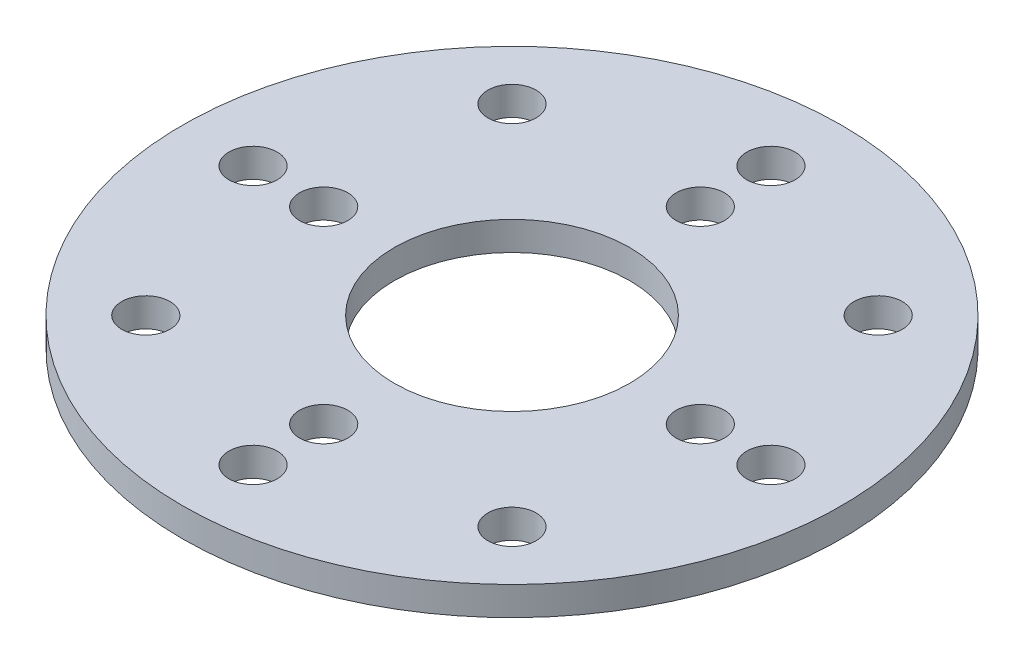
from build123d import *

# Parameters (mm, degrees)
SKETCH1_R           = 14
SKETCH1_R_2         = 1.025
SKETCH1_R_3         = 5
BOSS_EXTRUDE1_DEPTH = 1.22


with BuildPart() as part:
    # Sketch1 → Boss-Extrude1 (new body)
    with BuildSketch(Plane(origin=(0, 1.72, 0), x_dir=(1, 0, 0), z_dir=(0, 1, 0))):
        Circle(SKETCH1_R)
        with Locations((-8, 0)):
            Circle(SKETCH1_R_2, mode=Mode.SUBTRACT)
        with Locations((8, 0)):
            Circle(SKETCH1_R_2, mode=Mode.SUBTRACT)
        with Locations((-7.778174593, 7.778174593)):
            Circle(SKETCH1_R_2, mode=Mode.SUBTRACT)
        with Locations((-7.778174593, -7.778174593)):
            Circle(SKETCH1_R_2, mode=Mode.SUBTRACT)
        with Locations((7.778174593, -7.778174593)):
            Circle(SKETCH1_R_2, mode=Mode.SUBTRACT)
        with Locations((7.778174593, 7.778174593)):
            Circle(SKETCH1_R_2, mode=Mode.SUBTRACT)
        with Locations((0, 11)):
            Circle(SKETCH1_R_2, mode=Mode.SUBTRACT)
        with Locations((11, 0)):
            Circle(SKETCH1_R_2, mode=Mode.SUBTRACT)
        with Locations((0, -11)):
            Circle(SKETCH1_R_2, mode=Mode.SUBTRACT)
        with Locations((-11, 0)):
            Circle(SKETCH1_R_2, mode=Mode.SUBTRACT)
        with Locations((0, 8)):
            Circle(SKETCH1_R_2, mode=Mode.SUBTRACT)
        with Locations((0, -8)):
            Circle(SKETCH1_R_2, mode=Mode.SUBTRACT)
        Circle(SKETCH1_R_3, mode=Mode.SUBTRACT)
    extrude(amount=-BOSS_EXTRUDE1_DEPTH)


solid = part.part
